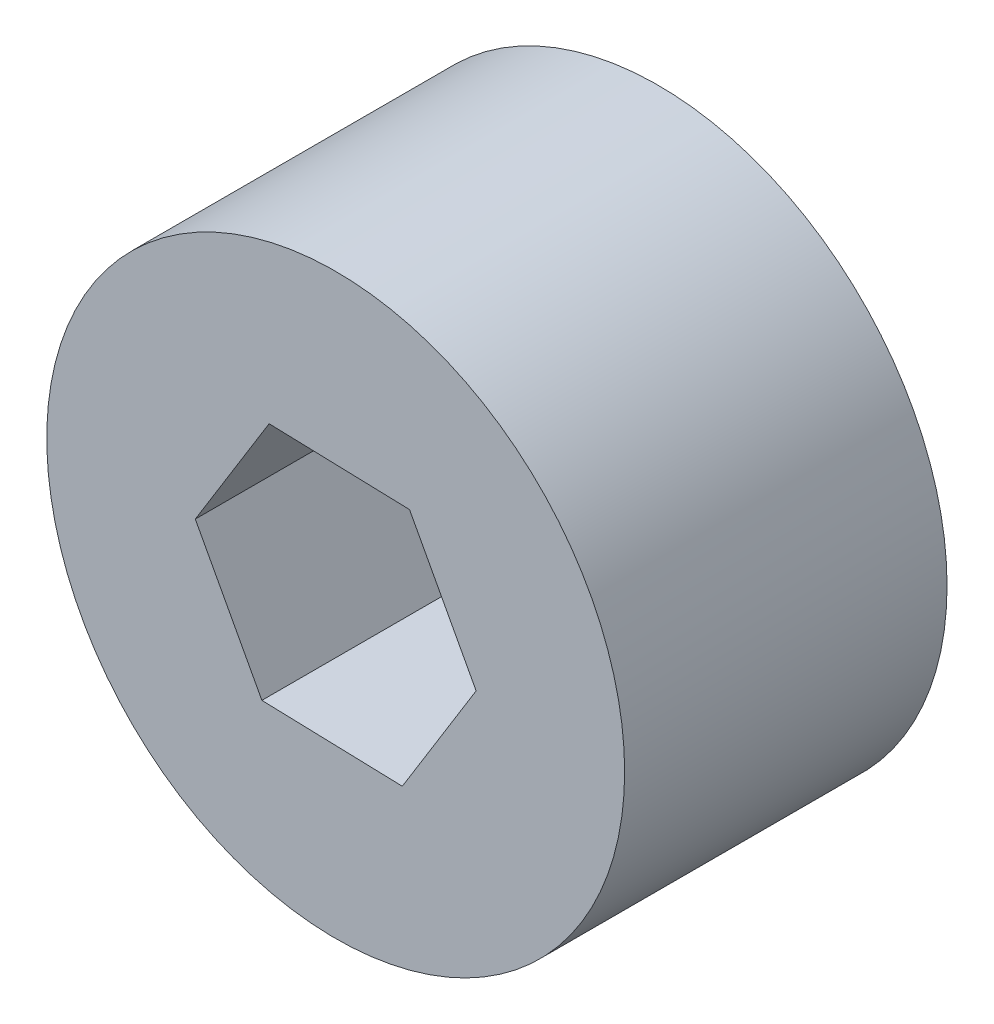
from build123d import *

# Parameters (mm, degrees)
SKETCH1_R           = 15.08125
BOSS_EXTRUDE1_DEPTH = 16.8275


with BuildPart() as part:
    # Sketch1 → Boss-Extrude1 (new body)
    with BuildSketch(Plane.XY):
        Circle(SKETCH1_R)
        Polygon((3.853096893, 6.238347351), (-3.476018837, 6.456053468), (-7.32911573, 0.217706117), (-3.853096893, -6.238347351), (3.476018837, -6.456053468), (7.32911573, -0.217706117), align=None, mode=Mode.SUBTRACT)
    extrude(amount=BOSS_EXTRUDE1_DEPTH)


solid = part.part
